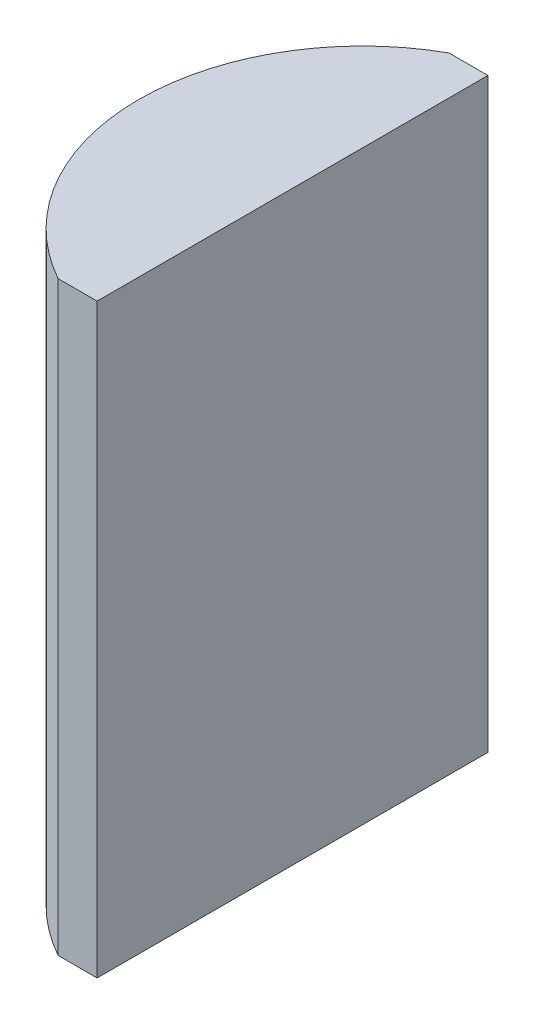
from build123d import *

# Parameters (mm, degrees)
EXTRUDE_1_DEPTH = 30


with BuildPart() as part:
    # 草图1 → 凸台-拉伸1 (new body)
    with BuildSketch(Plane(origin=(0, 0, 0), x_dir=(1, 0, 0), z_dir=(0, 1, 0))):
        with BuildLine():
            Line((-1.221757203, 10), (0.775204335, 10))
            Line((0.775204335, 10), (0.775204335, -10))
            Line((0.775204335, -10), (-1.221757203, -10))
            ThreePointArc((-1.221757203, -10), (-7.094795665, 0), (-1.221757203, 10))
        make_face()
    extrude(amount=EXTRUDE_1_DEPTH)


solid = part.part
